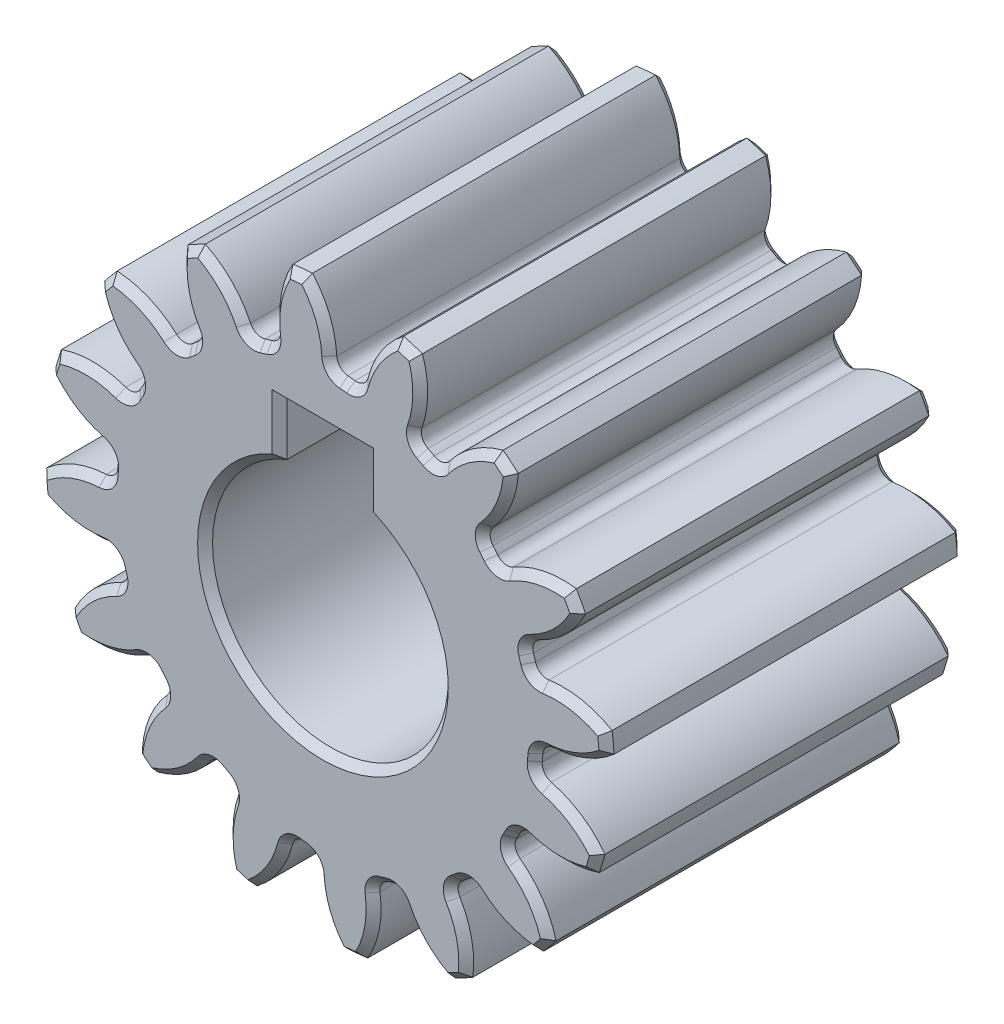
from build123d import *

# Parameters (mm, degrees)
SKETCH3_R          = 9.525
GEARBODY_DEPTH     = 12
TOOTHCUT_DEPTH     = 13
CIRPATTERN1_COUNT  = 16
BOREDIA_R          = 3.95
BORE_DEPTH         = 12700
SKETCH4_W          = 2.9
SKETCH4_H          = 3
CUT_EXTRUDE1_DEPTH = 13
CHAMFER1_SIZE      = 0.25


with BuildPart() as part:
    # Sketch3 → gearBody (new body)
    with BuildSketch(Plane.XY):
        Circle(SKETCH3_R)
    extrude(amount=GEARBODY_DEPTH)

    # Sketch2 → toothCut (cut, through all)
    with BuildSketch(Plane.XY):
        with BuildLine():
            ThreePointArc((7.098007151, -0.825654225), (7.110962737, -0.705421411), (7.121881853, -0.584986575))
            ThreePointArc((7.121881853, -0.584986575), (7.244448998, -0.326070493), (7.507360795, -0.212326792))
            ThreePointArc((7.507360795, -0.212326792), (8.942776091, 0.19912633), (10.04426967, 1.20730421))
            ThreePointArc((10.04426967, 1.20730421), (10.067153141, -0.99868128), (9.611304734, -3.157175632))
            ThreePointArc((9.611304734, -3.157175632), (8.729356694, -1.952236464), (7.40275638, -1.266785992))
            ThreePointArc((7.40275638, -1.266785992), (7.167316076, -1.103604788), (7.098007151, -0.825654225))
        make_face()
    toothcut = extrude(amount=TOOTHCUT_DEPTH, mode=Mode.SUBTRACT)

    # CirPattern1: toothCut ×16 about axis
    cirpattern1_axis = Axis((0, 0, 0), (0, 0, 1))
    for i in range(1, CIRPATTERN1_COUNT):
        add(toothcut.rotate(cirpattern1_axis, i * 360 / CIRPATTERN1_COUNT), mode=Mode.SUBTRACT)

    # boreDia → bore (cut, symmetric)
    with BuildSketch(Plane.XY):
        Circle(BOREDIA_R)
    extrude(amount=BORE_DEPTH, both=True, mode=Mode.SUBTRACT)

    # Sketch4 → Cut-Extrude1 (cut, through all)
    with BuildSketch(Plane(origin=(0, 0, 0), x_dir=(-1, 0, 0), z_dir=(0, 0, -1))):
        with Locations((0, 3.95)):
            Rectangle(SKETCH4_W, SKETCH4_H)
    extrude(amount=-CUT_EXTRUDE1_DEPTH, mode=Mode.SUBTRACT)

    # Chamfer1
    chamfer1_edges = [part.edges().sort_by_distance(p)[0] for p in [
        (8.575735729, 0.022864998, 12),
        (7.244448998, -0.326070493, 12),
        (7.110962737, -0.705421411, 12),
        (7.167316076, -1.103604788, 12),
        (8.404100183, -1.707297929, 12),
        (-7.931696773, 3.26066748, 12),
        (8.404100183, -1.707297929, 0),
        (-6.568216378, 3.073580463, 12),
        (-6.299719843, 3.372972031, 12),
        (-6.199405357, 3.762410992, 12),
        (-7.111021517, 4.793447517, 12),
        (-6.080128883, 6.047792893, 12),
        (-4.892032356, 5.35316567, 12),
        (-4.529401709, 5.527018235, 12),
        (-4.287691371, 5.848424229, 12),
        (-4.735354286, 7.149838172, 12),
        (-3.302916488, 7.914196661, 12),
        (-2.471080753, 6.817779929, 12),
        (-2.069523225, 6.839626016, 12),
        (-1.723215241, 7.044067893, 12),
        (-1.638772291, 8.41773078, 12),
        (-0.022864998, 8.575735729, 12),
        (0.326070493, 7.244448998, 12),
        (0.705421411, 7.110962737, 12),
        (1.103604788, 7.167316076, 12),
        (1.707297929, 8.404100183, 12),
        (3.26066748, 7.931696773, 12),
        (7.244448998, -0.326070493, 0),
        (3.073580463, 6.568216378, 12),
        (3.372972031, 6.299719843, 12),
        (3.762410992, 6.199405357, 12),
        (4.793447517, 7.111021517, 12),
        (6.047792893, 6.080128883, 12),
        (5.35316567, 4.892032356, 12),
        (5.527018235, 4.529401709, 12),
        (5.848424229, 4.287691371, 12),
        (7.149838172, 4.735354286, 12),
        (7.914196661, 3.302916488, 12),
        (6.817779929, 2.471080753, 12),
        (6.839626016, 2.069523225, 12),
        (7.044067893, 1.723215241, 12),
        (7.110962737, -0.705421411, 0),
        (8.41773078, 1.638772291, 12),
        (7.931696773, -3.26066748, 12),
        (6.568216378, -3.073580463, 12),
        (6.299719843, -3.372972031, 12),
        (6.199405357, -3.762410992, 12),
        (7.111021517, -4.793447517, 12),
        (6.080128883, -6.047792893, 12),
        (4.892032356, -5.35316567, 12),
        (4.529401709, -5.527018235, 12),
        (4.287691371, -5.848424229, 12),
        (4.735354286, -7.149838172, 12),
        (3.302916488, -7.914196661, 12),
        (2.471080753, -6.817779929, 12),
        (2.069523225, -6.839626016, 12),
        (7.167316076, -1.103604788, 0),
        (1.723215241, -7.044067893, 12),
        (1.638772291, -8.41773078, 12),
        (0.022864998, -8.575735729, 12),
        (-0.326070493, -7.244448998, 12),
        (-0.705421411, -7.110962737, 12),
        (-1.103604788, -7.167316076, 12),
        (-1.707297929, -8.404100183, 12),
        (-3.26066748, -7.931696773, 12),
        (-3.073580463, -6.568216378, 12),
        (-3.372972031, -6.299719843, 12),
        (-3.762410992, -6.199405357, 12),
        (-4.793447517, -7.111021517, 12),
        (-6.047792893, -6.080128883, 12),
        (-5.35316567, -4.892032356, 12),
        (-5.527018235, -4.529401709, 12),
        (-5.848424229, -4.287691371, 12),
        (-7.149838172, -4.735354286, 12),
        (-7.914196661, -3.302916488, 12),
        (-6.817779929, -2.471080753, 12),
        (-6.839626016, -2.069523225, 12),
        (-7.044067893, -1.723215241, 12),
        (-8.41773078, -1.638772291, 12),
        (-8.575735729, -0.022864998, 12),
        (-7.244448998, 0.326070493, 12),
        (-7.110962737, 0.705421411, 12),
        (-7.167316076, 1.103604788, 12),
        (-8.404100183, 1.707297929, 12),
        (7.111021517, -4.793447517, 0),
        (4.735354286, -7.149838172, 0),
        (1.638772291, -8.41773078, 0),
        (-1.707297929, -8.404100183, 0),
        (-4.793447517, -7.111021517, 0),
        (-7.149838172, -4.735354286, 0),
        (-8.41773078, -1.638772291, 0),
        (-8.404100183, 1.707297929, 0),
        (-7.111021517, 4.793447517, 0),
        (-4.735354286, 7.149838172, 0),
        (-1.638772291, 8.41773078, 0),
        (1.707297929, 8.404100183, 0),
        (4.793447517, 7.111021517, 0),
        (7.149838172, 4.735354286, 0),
        (8.41773078, 1.638772291, 0),
        (6.568216378, -3.073580463, 0),
        (6.299719843, -3.372972031, 0),
        (6.199405357, -3.762410992, 0),
        (4.892032356, -5.35316567, 0),
        (4.529401709, -5.527018235, 0),
        (4.287691371, -5.848424229, 0),
        (2.471080753, -6.817779929, 0),
        (2.069523225, -6.839626016, 0),
        (1.723215241, -7.044067893, 0),
        (-0.326070493, -7.244448998, 0),
        (-0.705421411, -7.110962737, 0),
        (-1.103604788, -7.167316076, 0),
        (9.479789137, 0.926942782, 0),
        (-3.073580463, -6.568216378, 0),
        (-3.372972031, -6.299719843, 0),
        (-3.762410992, -6.199405357, 0),
        (-5.35316567, -4.892032356, 0),
        (-5.527018235, -4.529401709, 0),
        (-5.848424229, -4.287691371, 0),
        (-6.817779929, -2.471080753, 0),
        (-6.839626016, -2.069523225, 0),
        (-7.044067893, -1.723215241, 0),
        (-7.244448998, 0.326070493, 0),
        (-7.110962737, 0.705421411, 0),
        (-7.167316076, 1.103604788, 0),
        (-6.568216378, 3.073580463, 0),
        (-6.299719843, 3.372972031, 0),
        (-6.199405357, 3.762410992, 0),
        (-4.892032356, 5.35316567, 0),
        (-4.529401709, 5.527018235, 0),
        (-4.287691371, 5.848424229, 0),
        (-2.471080753, 6.817779929, 0),
        (-2.069523225, 6.839626016, 0),
        (-1.723215241, 7.044067893, 0),
        (0.326070493, 7.244448998, 0),
        (0.705421411, 7.110962737, 0),
        (1.103604788, 7.167316076, 0),
        (3.073580463, 6.568216378, 0),
        (3.372972031, 6.299719843, 0),
        (3.762410992, 6.199405357, 0),
        (5.35316567, 4.892032356, 0),
        (5.527018235, 4.529401709, 0),
        (5.848424229, 4.287691371, 0),
        (6.817779929, 2.471080753, 0),
        (6.839626016, 2.069523225, 0),
        (7.044067893, 1.723215241, 0),
        (8.40345751, 4.484141709, 0),
        (6.047775656, 7.35867071, 0),
        (2.77137478, 9.112908802, 0),
        (-0.926942782, 9.479789137, 0),
        (-4.484141709, 8.40345751, 0),
        (-7.35867071, 6.047775656, 0),
        (-9.112908802, 2.77137478, 0),
        (-9.479789137, -0.926942782, 0),
        (-8.40345751, -4.484141709, 0),
        (-6.047775656, -7.35867071, 0),
        (-2.77137478, -9.112908802, 0),
        (0, -3.95, 12),
        (0, -3.95, 0),
        (0.926942782, -9.479789137, 0),
        (-1.45, 4.562117307, 12),
        (1.45, 4.562117307, 12),
        (1.45, 4.562117307, 0),
        (-1.45, 4.562117307, 0),
        (0, 5.45, 0),
        (0, 5.45, 12),
        (4.484141709, -8.40345751, 0),
        (7.35867071, -6.047775656, 0),
        (9.112908802, -2.77137478, 0),
        (9.479789137, 0.926942782, 12),
        (7.914196661, 3.302916488, 0),
        (6.047792893, 6.080128883, 0),
        (3.26066748, 7.931696773, 0),
        (-0.022864998, 8.575735729, 0),
        (-3.302916488, 7.914196661, 0),
        (-6.080128883, 6.047792893, 0),
        (-7.931696773, 3.26066748, 0),
        (-8.575735729, -0.022864998, 0),
        (8.575735729, 0.022864998, 0),
        (-7.914196661, -3.302916488, 0),
        (-6.047792893, -6.080128883, 0),
        (-3.26066748, -7.931696773, 0),
        (0.022864998, -8.575735729, 0),
        (3.302916488, -7.914196661, 0),
        (6.080128883, -6.047792893, 0),
        (7.931696773, -3.26066748, 0),
        (8.40345751, 4.484141709, 12),
        (6.047775656, 7.35867071, 12),
        (2.77137478, 9.112908802, 12),
        (-0.926942782, 9.479789137, 12),
        (-4.484141709, 8.40345751, 12),
        (-7.35867071, 6.047775656, 12),
        (-9.112908802, 2.77137478, 12),
        (-9.479789137, -0.926942782, 12),
        (-8.40345751, -4.484141709, 12),
        (-6.047775656, -7.35867071, 12),
        (-2.77137478, -9.112908802, 12),
        (0.926942782, -9.479789137, 12),
        (4.484141709, -8.40345751, 12),
        (7.35867071, -6.047775656, 12),
        (9.112908802, -2.77137478, 12),
    ]]
    chamfer(chamfer1_edges, length=CHAMFER1_SIZE)


solid = part.part
